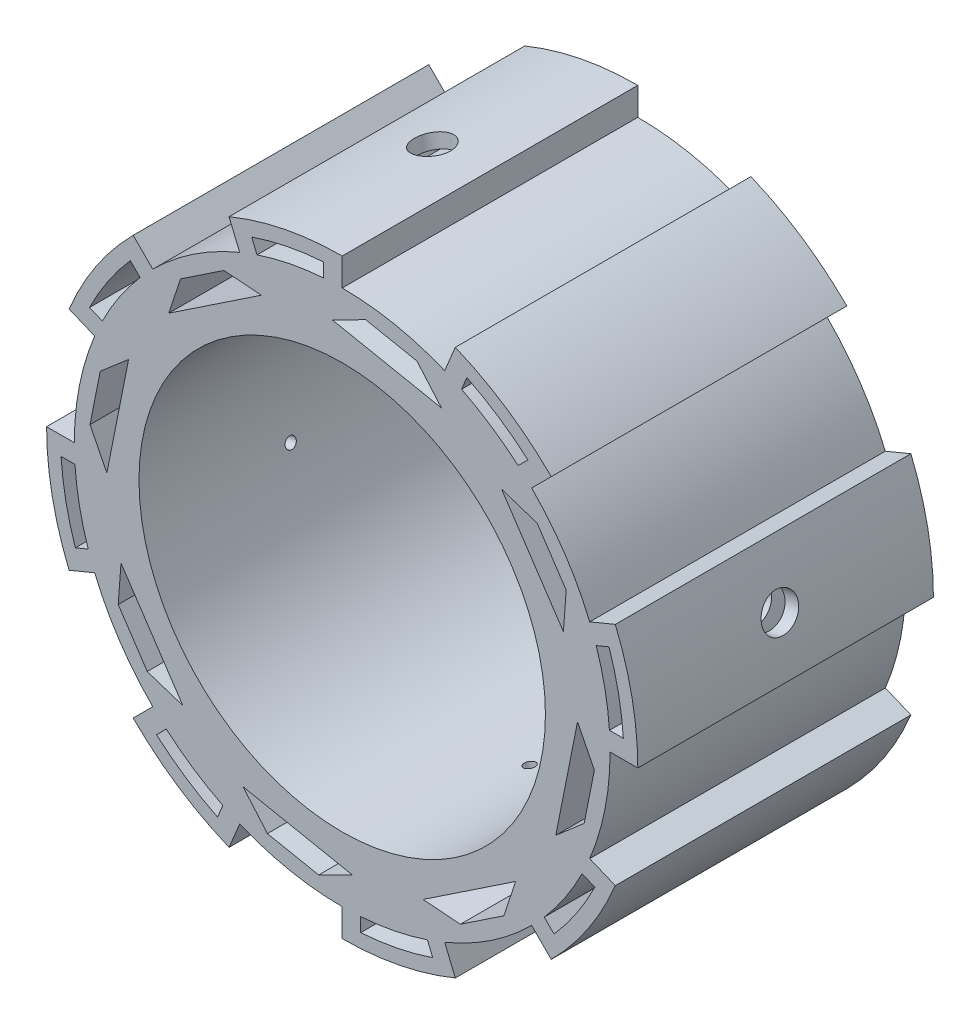
from build123d import *

# Parameters (mm, degrees)
BOSS_EXTRUDE1_DEPTH     = 80
SKETCH2_R               = 55
CUT_EXTRUDE1_DEPTH      = 67
CUT_EXTRUDE1_DEPTH_BACK = 127
CUT_EXTRUDE2_DEPTH      = 21
CUT_EXTRUDE2_DEPTH_BACK = 103
CUT_EXTRUDE3_DEPTH      = 36
CUT_EXTRUDE3_DEPTH_BACK = 105
CUT_EXTRUDE4_DEPTH      = 15
CUT_EXTRUDE5_DEPTH      = 15
CUT_EXTRUDE6_DEPTH      = 15
CUT_EXTRUDE7_DEPTH      = 15
SKETCH18_R              = 1.5
M3_HOLE1_DEPTH          = 190
SKETCH19_R              = 1.5
M3_HOLE2_DEPTH          = 190


with BuildPart() as part:
    # Base Drawing → Boss-Extrude1 (new body)
    with BuildSketch(Plane.XY):
        with BuildLine():
            Line((0, 72.5), (0, 80))
            ThreePointArc((0, 80), (-15.607225761, 78.462822432), (-30.614674589, 73.910362601))
            Line((-30.614674589, 73.910362601), (-27.744548846, 66.981266107))
            Line((-27.744548846, 66.981266107), (-25.632620818, 61.882620818))
            Line((-25.632620818, 61.882620818), (0, 0))
            Line((0, 0), (0, 72.5))
        make_face()
        with BuildLine():
            Line((-51.265241636, 51.265241636), (0, 0))
            Line((0, 0), (-25.632620818, 61.882620818))
            Line((-25.632620818, 61.882620818), (-27.744548846, 66.981266107))
            ThreePointArc((-27.744548846, 66.981266107), (-40.278841894, 60.281546892), (-51.265241636, 51.265241636))
        make_face()
        with BuildLine():
            Line((-61.882620818, 25.632620818), (0, 0))
            Line((0, 0), (-51.265241636, 51.265241636))
            Line((-51.265241636, 51.265241636), (-56.568542495, 56.568542495))
            ThreePointArc((-56.568542495, 56.568542495), (-66.517568984, 44.445618642), (-73.910362601, 30.614674589))
            Line((-73.910362601, 30.614674589), (-66.981266107, 27.744548846))
            Line((-66.981266107, 27.744548846), (-61.882620818, 25.632620818))
        make_face()
        with BuildLine():
            Line((-72.5, 0), (0, 0))
            Line((0, 0), (-61.882620818, 25.632620818))
            Line((-61.882620818, 25.632620818), (-66.981266107, 27.744548846))
            ThreePointArc((-66.981266107, 27.744548846), (-71.106932829, 14.144048346), (-72.5, 0))
        make_face()
        with BuildLine():
            Line((-61.882620818, -25.632620818), (0, 0))
            Line((0, 0), (-72.5, 0))
            Line((-72.5, 0), (-80, 0))
            ThreePointArc((-80, 0), (-78.462822432, -15.607225761), (-73.910362601, -30.614674589))
            Line((-73.910362601, -30.614674589), (-66.981266107, -27.744548846))
            Line((-66.981266107, -27.744548846), (-61.882620818, -25.632620818))
        make_face()
        with BuildLine():
            Line((-51.265241636, -51.265241636), (0, 0))
            Line((0, 0), (-61.882620818, -25.632620818))
            Line((-61.882620818, -25.632620818), (-66.981266107, -27.744548846))
            ThreePointArc((-66.981266107, -27.744548846), (-60.281546892, -40.278841894), (-51.265241636, -51.265241636))
        make_face()
        with BuildLine():
            Line((-25.632620818, -61.882620818), (0, 0))
            Line((0, 0), (-51.265241636, -51.265241636))
            Line((-51.265241636, -51.265241636), (-56.568542495, -56.568542495))
            ThreePointArc((-56.568542495, -56.568542495), (-44.445618642, -66.517568984), (-30.614674589, -73.910362601))
            Line((-30.614674589, -73.910362601), (-27.744548846, -66.981266107))
            Line((-27.744548846, -66.981266107), (-25.632620818, -61.882620818))
        make_face()
        with BuildLine():
            Line((0, -72.5), (0, 0))
            Line((0, 0), (-25.632620818, -61.882620818))
            Line((-25.632620818, -61.882620818), (-27.744548846, -66.981266107))
            ThreePointArc((-27.744548846, -66.981266107), (-14.144048346, -71.106932829), (0, -72.5))
        make_face()
        with BuildLine():
            Line((27.744548846, -66.981266107), (0, 0))
            Line((0, 0), (0, -72.5))
            Line((0, -72.5), (0, -80))
            ThreePointArc((0, -80), (15.607225761, -78.462822432), (30.614674589, -73.910362601))
            Line((30.614674589, -73.910362601), (27.744548846, -66.981266107))
        make_face()
        with BuildLine():
            Line((51.265241636, -51.265241636), (0, 0))
            Line((0, 0), (27.744548846, -66.981266107))
            ThreePointArc((27.744548846, -66.981266107), (40.278841894, -60.281546892), (51.265241636, -51.265241636))
        make_face()
        with BuildLine():
            Line((66.981266107, -27.744548846), (0, 0))
            Line((0, 0), (51.265241636, -51.265241636))
            Line((51.265241636, -51.265241636), (56.568542495, -56.568542495))
            ThreePointArc((56.568542495, -56.568542495), (66.517568984, -44.445618642), (73.910362601, -30.614674589))
            Line((73.910362601, -30.614674589), (66.981266107, -27.744548846))
        make_face()
        with BuildLine():
            Line((72.5, 0), (0, 0))
            Line((0, 0), (66.981266107, -27.744548846))
            ThreePointArc((66.981266107, -27.744548846), (71.106932829, -14.144048346), (72.5, 0))
        make_face()
        with BuildLine():
            Line((66.981266107, 27.744548846), (0, 0))
            Line((0, 0), (72.5, 0))
            Line((72.5, 0), (80, 0))
            ThreePointArc((80, 0), (78.462822432, 15.607225761), (73.910362601, 30.614674589))
            Line((73.910362601, 30.614674589), (66.981266107, 27.744548846))
        make_face()
        with BuildLine():
            Line((51.265241636, 51.265241636), (0, 0))
            Line((0, 0), (66.981266107, 27.744548846))
            ThreePointArc((66.981266107, 27.744548846), (60.281546892, 40.278841894), (51.265241636, 51.265241636))
        make_face()
        with BuildLine():
            Line((25.632620818, 61.882620818), (0, 0))
            Line((0, 0), (51.265241636, 51.265241636))
            Line((51.265241636, 51.265241636), (56.568542495, 56.568542495))
            ThreePointArc((56.568542495, 56.568542495), (44.445618642, 66.517568984), (30.614674589, 73.910362601))
            Line((30.614674589, 73.910362601), (27.744548846, 66.981266107))
            Line((27.744548846, 66.981266107), (25.632620818, 61.882620818))
        make_face()
        with BuildLine():
            ThreePointArc((27.744548846, 66.981266107), (14.144048346, 71.106932829), (0, 72.5))
            Line((0, 72.5), (0, 0))
            Line((0, 0), (25.632620818, 61.882620818))
            Line((25.632620818, 61.882620818), (27.744548846, 66.981266107))
        make_face()
    extrude(amount=BOSS_EXTRUDE1_DEPTH)

    # Sketch2 → Cut-Extrude1 (cut, two sides)
    with BuildSketch(Plane.XY.offset(80)) as cut_extrude1_sk:
        Circle(SKETCH2_R)
    extrude(amount=CUT_EXTRUDE1_DEPTH, mode=Mode.SUBTRACT)
    extrude(cut_extrude1_sk.sketch, amount=-CUT_EXTRUDE1_DEPTH_BACK, mode=Mode.SUBTRACT)

    # Sketch3 → Cut-Extrude2 (cut, two sides)
    with BuildSketch(Plane(origin=(0, 0, 0), x_dir=(-1, 0, 0), z_dir=(0, 0, -1))) as cut_extrude2_sk:
        with BuildLine():
            Line((-32.297887966, 64.908369514), (-32.363946509, 65.067848945))
            Line((-32.363946509, 65.067848945), (-33.156509848, 66.981266107))
            Line((-33.156509848, 66.981266107), (-33.736206807, 68.380778368))
            ThreePointArc((-33.736206807, 68.380778368), (-42.362230268, 63.399557938), (-50.265314136, 57.336381948))
            Line((-50.265314136, 57.336381948), (-49.203804332, 56.274872144))
            Line((-49.203804332, 56.274872144), (-47.72970773, 54.800775542))
            Line((-47.72970773, 54.800775542), (-47.607647458, 54.67871527))
            ThreePointArc((-47.607647458, 54.67871527), (-40.278841894, 60.281546892), (-32.297887966, 64.908369514))
        make_face()
        with BuildLine():
            Line((-68.735203838, 23.059092641), (-68.894683269, 23.125151184))
            Line((-68.894683269, 23.125151184), (-71.001371746, 23.997770123))
            Line((-71.001371746, 23.997770123), (-72.207612692, 24.497411482))
            ThreePointArc((-72.207612692, 24.497411482), (-74.784877631, 14.875637054), (-76.085888968, 5))
            Line((-76.085888968, 5), (-74.668691299, 5))
            Line((-74.668691299, 5), (-72.5, 5))
            Line((-72.5, 5), (-72.327380707, 5))
            ThreePointArc((-72.327380707, 5), (-71.106932829, 14.144048346), (-68.735203838, 23.059092641))
        make_face()
        with BuildLine():
            Line((-64.908369514, -32.297887966), (-65.067848945, -32.363946509))
            Line((-65.067848945, -32.363946509), (-66.981266107, -33.156509848))
            Line((-66.981266107, -33.156509848), (-68.363511265, -33.729054539))
            Line((-68.363511265, -33.729054539), (-68.380778368, -33.736206807))
            ThreePointArc((-68.380778368, -33.736206807), (-63.399557938, -42.362230268), (-57.336381948, -50.265314136))
            Line((-57.336381948, -50.265314136), (-56.25693439, -49.185866578))
            Line((-56.25693439, -49.185866578), (-54.800775542, -47.72970773))
            Line((-54.800775542, -47.72970773), (-54.67871527, -47.607647458))
            ThreePointArc((-54.67871527, -47.607647458), (-60.281546892, -40.278841894), (-64.908369514, -32.297887966))
        make_face()
        with BuildLine():
            ThreePointArc((-24.497411482, -72.207612692), (-14.875637054, -74.784877631), (-5, -76.085888968))
            Line((-5, -76.085888968), (-5, -75.365107954))
            Line((-5, -75.365107954), (-5, -74.464091379))
            Line((-5, -74.464091379), (-5, -72.5))
            Line((-5, -72.5), (-5, -72.327380707))
            ThreePointArc((-5, -72.327380707), (-14.144048346, -71.106932829), (-23.059092641, -68.735203838))
            Line((-23.059092641, -68.735203838), (-23.125151184, -68.894683269))
            Line((-23.125151184, -68.894683269), (-23.932515407, -70.843832926))
            Line((-23.932515407, -70.843832926), (-24.417934118, -72.015737361))
            Line((-24.417934118, -72.015737361), (-24.497411482, -72.207612692))
        make_face()
        with BuildLine():
            Line((48.47079588, -55.541863692), (47.72970773, -54.800775542))
            Line((47.72970773, -54.800775542), (47.607647458, -54.67871527))
            ThreePointArc((47.607647458, -54.67871527), (40.278841894, -60.281546892), (32.297887966, -64.908369514))
            Line((32.297887966, -64.908369514), (32.363946509, -65.067848945))
            Line((32.363946509, -65.067848945), (32.936166208, -66.449309504))
            Line((32.936166208, -66.449309504), (33.603941902, -68.061462639))
            Line((33.603941902, -68.061462639), (33.736206807, -68.380778368))
            ThreePointArc((33.736206807, -68.380778368), (42.362230268, -63.399557938), (50.265314136, -57.336381948))
            Line((50.265314136, -57.336381948), (48.47079588, -55.541863692))
        make_face()
        with BuildLine():
            Line((75.823779763, -5), (72.5, -5))
            Line((72.5, -5), (72.337295851, -5))
            Line((72.337295851, -5), (72.327380707, -5))
            ThreePointArc((72.327380707, -5), (71.106932829, -14.144048346), (68.735203838, -23.059092641))
            Line((68.735203838, -23.059092641), (68.894683269, -23.125151184))
            Line((68.894683269, -23.125151184), (69.253006962, -23.273573717))
            Line((69.253006962, -23.273573717), (70.382632906, -23.741480104))
            Line((70.382632906, -23.741480104), (72.207612692, -24.497411482))
            ThreePointArc((72.207612692, -24.497411482), (74.784877631, -14.875637054), (76.085888968, -5))
            Line((76.085888968, -5), (75.823779763, -5))
        make_face()
        with BuildLine():
            Line((56.184348869, 49.113281057), (54.800775542, 47.72970773))
            Line((54.800775542, 47.72970773), (54.679998373, 47.608930561))
            Line((54.679998373, 47.608930561), (54.67871527, 47.607647458))
            ThreePointArc((54.67871527, 47.607647458), (60.281546892, 40.278841894), (64.908369514, 32.297887966))
            Line((64.908369514, 32.297887966), (65.067848945, 32.363946509))
            Line((65.067848945, 32.363946509), (65.431620873, 32.514625775))
            Line((65.431620873, 32.514625775), (66.336433936, 32.889411617))
            Line((66.336433936, 32.889411617), (68.380778368, 33.736206807))
            ThreePointArc((68.380778368, 33.736206807), (63.399557938, 42.362230268), (57.336381948, 50.265314136))
            Line((57.336381948, 50.265314136), (56.184348869, 49.113281057))
        make_face()
        with BuildLine():
            Line((23.059092641, 68.735203838), (23.125151184, 68.894683269))
            Line((23.125151184, 68.894683269), (24.132904336, 71.327614596))
            Line((24.132904336, 71.327614596), (24.497411482, 72.207612692))
            ThreePointArc((24.497411482, 72.207612692), (14.875637054, 74.784877631), (5, 76.085888968))
            Line((5, 76.085888968), (5, 74.952220789))
            Line((5, 74.952220789), (5, 72.5))
            Line((5, 72.5), (5, 72.327380707))
            ThreePointArc((5, 72.327380707), (14.144048346, 71.106932829), (23.059092641, 68.735203838))
        make_face()
    extrude(amount=CUT_EXTRUDE2_DEPTH, mode=Mode.SUBTRACT)
    extrude(cut_extrude2_sk.sketch, amount=-CUT_EXTRUDE2_DEPTH_BACK, mode=Mode.SUBTRACT)

    # Sketch5 → Cut-Extrude3 (cut, two sides)
    with BuildSketch(Plane(origin=(0, 0, 0), x_dir=(-1, 0, 0), z_dir=(0, 0, -1))) as cut_extrude3_sk:
        Polygon((-55.940927069, 27.758983606), (-54.251958897, 36.25), (-60.616612502, 31.997274423), (-59.869933187, 21.878810409), align=None)
        Polygon((-47.053622778, 41.059774423), (-54.251958897, 36.25), (-55.940927069, 27.758983606), align=None)
        Polygon((-43.12461666, 46.939947621), (-52.758600266, 43.757620818), (-54.251958897, 36.25), (-47.053622778, 41.059774423), align=None)
        Polygon((-54.251958897, 36.25), (-52.758600266, 43.757620818), (-60.616612502, 31.997274423), align=None)
        Polygon((-12.72930721, 63.994548846), (-20.236928028, 65.487907477), (-26.863780541, 57.80509095), (-19.927643329, 59.184774423), align=None)
        Polygon((-6.364653605, 68.247274423), (-20.236928028, 65.487907477), (-12.72930721, 63.994548846), align=None)
        Polygon((-6.364653605, 68.247274423), (-12.72930721, 63.994548846), (-4.238290817, 62.305580674), (2.697846395, 63.685264147), align=None)
        Polygon((-4.238290817, 62.305580674), (-12.72930721, 63.994548846), (-19.927643329, 59.184774423), align=None)
        Polygon((36.25, 54.251958897), (31.997274423, 60.616612502), (21.878810409, 59.869933187), (27.758983606, 55.940927069), align=None)
        Polygon((34.409379015, 51.497274923), (36.25, 54.251958897), (27.758983606, 55.940927069), align=None)
        Polygon((43.757620818, 52.758600266), (36.25, 54.251958897), (41.059774423, 47.053622778), (46.939947621, 43.12461666), align=None)
        Polygon((37.877447621, 56.687606384), (36.25, 54.251958897), (43.757620818, 52.758600266), align=None)
        Polygon((37.877447621, 56.687606384), (31.997274423, 60.616612502), (36.25, 54.251958897), align=None)
        Polygon((41.059774423, 47.053622778), (36.25, 54.251958897), (34.409379015, 51.497274923), align=None)
        Polygon((68.247274423, 6.364653605), (63.994548846, 12.72930721), (62.305580674, 4.238290817), (63.685264147, -2.697846395), align=None)
        Polygon((63.994548846, 12.72930721), (59.184774423, 19.927643329), (62.305580674, 4.238290817), align=None)
        Polygon((63.994548846, 12.72930721), (65.487907477, 20.236928028), (57.80509095, 26.863780541), (59.184774423, 19.927643329), align=None)
        Polygon((66.86759095, 13.300790817), (65.487907477, 20.236928028), (63.994548846, 12.72930721), align=None)
        Polygon((66.86759095, 13.300790817), (63.994548846, 12.72930721), (68.247274423, 6.364653605), align=None)
        Polygon((56.687606384, -37.877447621), (54.251958897, -36.25), (52.758600266, -43.757620818), align=None)
        Polygon((56.687606384, -37.877447621), (60.616612502, -31.997274423), (54.251958897, -36.25), align=None)
        Polygon((54.251958897, -36.25), (60.616612502, -31.997274423), (59.869933187, -21.878810409), (55.940927069, -27.758983606), align=None)
        Polygon((54.251958897, -36.25), (55.940927069, -27.758983606), (47.053622778, -41.059774423), align=None)
        Polygon((52.758600266, -43.757620818), (54.251958897, -36.25), (47.053622778, -41.059774423), (43.12461666, -46.939947621), align=None)
        Polygon((-2.697846395, -63.685264147), (6.364653605, -68.247274423), (12.72930721, -63.994548846), (4.238290817, -62.305580674), align=None)
        Polygon((12.72930721, -63.994548846), (6.364653605, -68.247274423), (13.300790817, -66.86759095), align=None)
        Polygon((20.236928028, -65.487907477), (12.72930721, -63.994548846), (13.300790817, -66.86759095), align=None)
        Polygon((19.927643329, -59.184774423), (12.72930721, -63.994548846), (20.236928028, -65.487907477), (26.863780541, -57.80509095), align=None)
        Polygon((19.927643329, -59.184774423), (4.238290817, -62.305580674), (12.72930721, -63.994548846), align=None)
        Polygon((-46.939947621, -43.12461666), (-43.757620818, -52.758600266), (-36.25, -54.251958897), (-41.059774423, -47.053622778), align=None)
        Polygon((-36.25, -54.251958897), (-43.757620818, -52.758600266), (-37.877447621, -56.687606384), align=None)
        Polygon((-31.997274423, -60.616612502), (-36.25, -54.251958897), (-37.877447621, -56.687606384), align=None)
        Polygon((-27.758983606, -55.940927069), (-36.25, -54.251958897), (-31.997274423, -60.616612502), (-21.878810409, -59.869933187), align=None)
        Polygon((-41.059774423, -47.053622778), (-36.25, -54.251958897), (-27.758983606, -55.940927069), align=None)
        Polygon((-63.685264147, 2.697846395), (-68.247274423, -6.364653605), (-63.994548846, -12.72930721), (-62.305580674, -4.238290817), align=None)
        Polygon((-63.994548846, -12.72930721), (-68.247274423, -6.364653605), (-65.487907477, -20.236928028), align=None)
        Polygon((-59.184774423, -19.927643329), (-63.994548846, -12.72930721), (-65.487907477, -20.236928028), (-57.80509095, -26.863780541), align=None)
        Polygon((-62.305580674, -4.238290817), (-63.994548846, -12.72930721), (-59.184774423, -19.927643329), align=None)
    extrude(amount=CUT_EXTRUDE3_DEPTH, mode=Mode.SUBTRACT)
    extrude(cut_extrude3_sk.sketch, amount=-CUT_EXTRUDE3_DEPTH_BACK, mode=Mode.SUBTRACT)

    # Sketch14 → Cut-Extrude4 (cut)
    with BuildSketch(Plane(origin=(78.462822432, 15.607225761, 0), x_dir=(0, 0, -1), z_dir=(0.98078528, 0.195090322, 0))):
        with BuildLine():
            ThreePointArc((-45, 0), (-40, -5), (-35, 0))
            Line((-35, 0), (-45, 0))
        make_face()
        with BuildLine():
            Line((-45, 0), (-35, 0))
            ThreePointArc((-35, 0), (-40, 5), (-45, 0))
        make_face()
    extrude(amount=-CUT_EXTRUDE4_DEPTH, mode=Mode.SUBTRACT)

    # Sketch15 → Cut-Extrude5 (cut)
    with BuildSketch(Plane(origin=(-78.462822432, -15.607225761, 0), x_dir=(0, 0, -1), z_dir=(-0.98078528, -0.195090322, 0))):
        with BuildLine():
            ThreePointArc((-45, 0), (-40, -5), (-35, 0))
            Line((-35, 0), (-45, 0))
        make_face()
        with BuildLine():
            Line((-45, 0), (-35, 0))
            ThreePointArc((-35, 0), (-40, 5), (-45, 0))
        make_face()
    extrude(amount=-CUT_EXTRUDE5_DEPTH, mode=Mode.SUBTRACT)

    # Sketch16 → Cut-Extrude6 (cut)
    with BuildSketch(Plane(origin=(-15.607225761, 78.462822432, 0), x_dir=(0, 0, -1), z_dir=(-0.195090322, 0.98078528, 0))):
        with BuildLine():
            ThreePointArc((-45, 0), (-40, -5), (-35, 0))
            Line((-35, 0), (-45, 0))
        make_face()
        with BuildLine():
            Line((-45, 0), (-35, 0))
            ThreePointArc((-35, 0), (-40, 5), (-45, 0))
        make_face()
    extrude(amount=-CUT_EXTRUDE6_DEPTH, mode=Mode.SUBTRACT)

    # Sketch17 → Cut-Extrude7 (cut)
    with BuildSketch(Plane(origin=(15.607225761, -78.462822432, 0), x_dir=(0, 0, -1), z_dir=(0.195090322, -0.98078528, 0))):
        with BuildLine():
            ThreePointArc((-45, 0), (-40, -5), (-35, 0))
            Line((-35, 0), (-45, 0))
        make_face()
        with BuildLine():
            Line((-45, 0), (-35, 0))
            ThreePointArc((-35, 0), (-40, 5), (-45, 0))
        make_face()
    extrude(amount=-CUT_EXTRUDE7_DEPTH, mode=Mode.SUBTRACT)

    # Sketch18 → M3 Hole1 (cut)
    with BuildSketch(Plane(origin=(78.462822432, 15.607225761, 0), x_dir=(0, 0, -1), z_dir=(0.98078528, 0.195090322, 0))):
        with Locations((-40, 0)):
            Circle(SKETCH18_R)
    extrude(amount=-M3_HOLE1_DEPTH, mode=Mode.SUBTRACT)

    # Sketch19 → M3 Hole2 (cut)
    with BuildSketch(Plane(origin=(-15.607225761, 78.462822432, 0), x_dir=(0, 0, -1), z_dir=(-0.195090322, 0.98078528, 0))):
        with Locations((-40, 0)):
            Circle(SKETCH19_R)
    extrude(amount=-M3_HOLE2_DEPTH, mode=Mode.SUBTRACT)


solid = part.part
